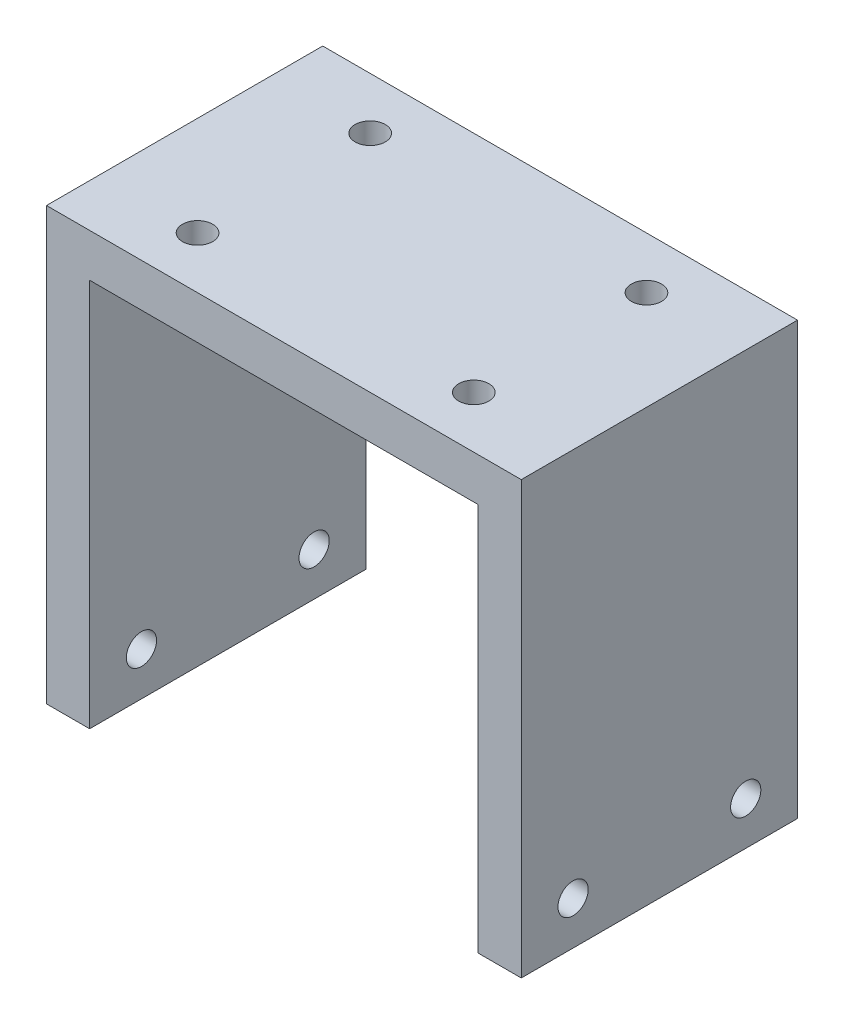
from build123d import *

# Parameters (mm, degrees)
SKETCH1_W           = 55
SKETCH1_H           = 32
BOSS_EXTRUDE1_DEPTH = 50
SKETCH2_W           = 45
SKETCH2_H           = 32
CUT_EXTRUDE1_DEPTH  = 45
SKETCH3_R           = 1.75
CUT_EXTRUDE2_DEPTH  = 51
SKETCH4_R           = 1.75
CUT_EXTRUDE3_DEPTH  = 56
SKETCH5_W           = 1.1
SKETCH5_H           = 35
CUT_EXTRUDE4_DEPTH  = 1.2


with BuildPart() as part:
    # Sketch1 → Boss-Extrude1 (new body)
    with BuildSketch(Plane(origin=(0, 0, 0), x_dir=(1, 0, 0), z_dir=(0, 1, 0))):
        with Locations((27.5, 16)):
            Rectangle(SKETCH1_W, SKETCH1_H)
    extrude(amount=BOSS_EXTRUDE1_DEPTH)

    # Sketch2 → Cut-Extrude1 (cut)
    with BuildSketch(Plane.XZ):
        with Locations((27.5, -16)):
            Rectangle(SKETCH2_W, SKETCH2_H)
    extrude(amount=-CUT_EXTRUDE1_DEPTH, mode=Mode.SUBTRACT)

    # Sketch3 → Cut-Extrude2 (cut, through all)
    with BuildSketch(Plane(origin=(0, 50, 0), x_dir=(1, 0, 0), z_dir=(0, 1, 0))):
        with Locations((43.5, 26)):
            Circle(SKETCH3_R)
        with Locations((43.5, 6)):
            Circle(SKETCH3_R)
        with Locations((11.5, 26)):
            Circle(SKETCH3_R)
        with Locations((11.5, 6)):
            Circle(SKETCH3_R)
    extrude(amount=-CUT_EXTRUDE2_DEPTH, mode=Mode.SUBTRACT)

    # Sketch4 → Cut-Extrude3 (cut, through all)
    with BuildSketch(Plane(origin=(55, 0, 0), x_dir=(0, 0, -1), z_dir=(1, 0, 0))):
        with Locations((6, 5)):
            Circle(SKETCH4_R)
        with Locations((26, 5)):
            Circle(SKETCH4_R)
    extrude(amount=-CUT_EXTRUDE3_DEPTH, mode=Mode.SUBTRACT)

    # Sketch5 → Cut-Extrude4 (cut)
    with BuildSketch(Plane.ZY.offset(-50)):
        with Locations((-29.45, 27.5)):
            Rectangle(SKETCH5_W, SKETCH5_H)
        with Locations((-31.45, 27.5)):
            Rectangle(SKETCH5_W, SKETCH5_H)
        with Locations((-27.45, 27.5)):
            Rectangle(SKETCH5_W, SKETCH5_H)
        with Locations((-25.45, 27.5)):
            Rectangle(SKETCH5_W, SKETCH5_H)
        with Locations((-23.45, 27.5)):
            Rectangle(SKETCH5_W, SKETCH5_H)
        with Locations((-21.45, 27.5)):
            Rectangle(SKETCH5_W, SKETCH5_H)
        with Locations((-19.45, 27.5)):
            Rectangle(SKETCH5_W, SKETCH5_H)
        with Locations((-17.45, 27.5)):
            Rectangle(SKETCH5_W, SKETCH5_H)
        with Locations((-15.45, 27.5)):
            Rectangle(SKETCH5_W, SKETCH5_H)
        with Locations((-13.45, 27.5)):
            Rectangle(SKETCH5_W, SKETCH5_H)
        with Locations((-11.45, 27.5)):
            Rectangle(SKETCH5_W, SKETCH5_H)
        with Locations((-9.45, 27.5)):
            Rectangle(SKETCH5_W, SKETCH5_H)
        with Locations((-7.45, 27.5)):
            Rectangle(SKETCH5_W, SKETCH5_H)
        with Locations((-5.45, 27.5)):
            Rectangle(SKETCH5_W, SKETCH5_H)
        with Locations((-3.45, 27.5)):
            Rectangle(SKETCH5_W, SKETCH5_H)
        with Locations((-1.45, 27.5)):
            Rectangle(SKETCH5_W, SKETCH5_H)
        with Locations((0.55, 27.5)):
            Rectangle(SKETCH5_W, SKETCH5_H)
    extrude(amount=-CUT_EXTRUDE4_DEPTH, mode=Mode.SUBTRACT)


solid = part.part
